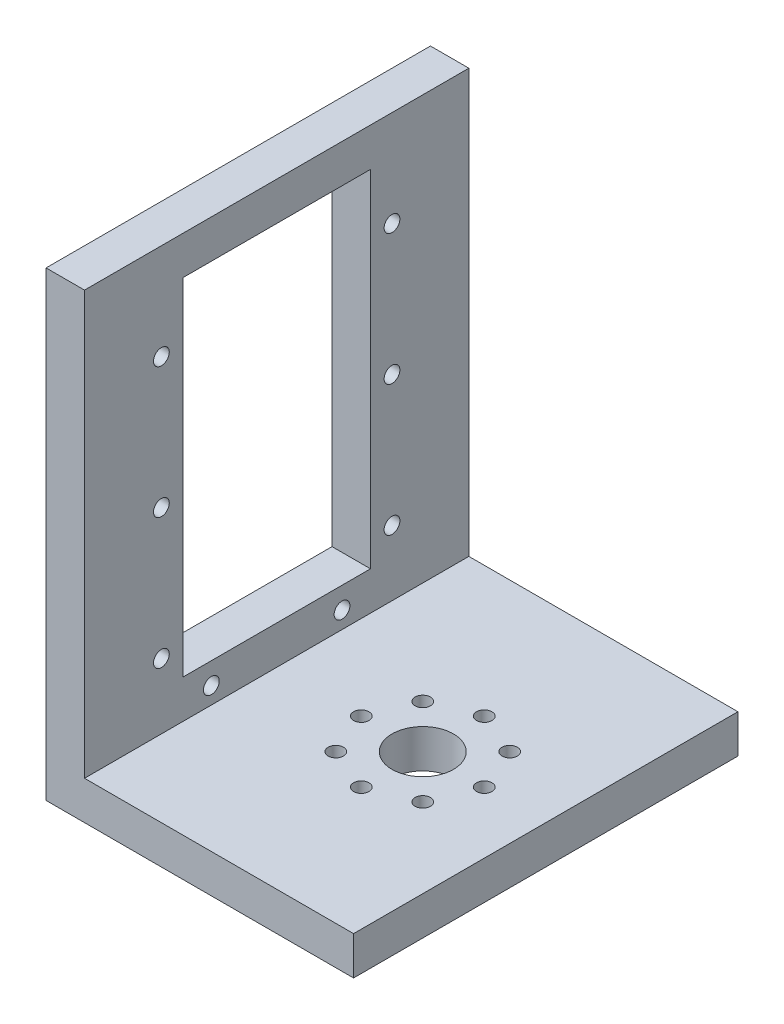
from build123d import *

# Parameters (mm, degrees)
SKETCH1_W           = 40
SKETCH1_H           = 50
SKETCH1_R           = 4
SKETCH1_R_2         = 1
BOSS_EXTRUDE1_DEPTH = 5
SKETCH3_W           = 5
SKETCH3_H           = 50
BOSS_EXTRUDE2_DEPTH = 60
SKETCH4_R           = 1.025
SKETCH4_W           = 24.4
SKETCH4_H           = 45
CUT_EXTRUDE1_DEPTH  = 41


with BuildPart() as part:
    # Sketch1 → Boss-Extrude1 (new body)
    with BuildSketch(Plane(origin=(0, 0, 0), x_dir=(1, 0, 0), z_dir=(0, 1, 0))):
        with Locations((20, 25)):
            Rectangle(SKETCH1_W, SKETCH1_H)
        with Locations((24, 25)):
            Circle(SKETCH1_R, mode=Mode.SUBTRACT)
        with Locations((24, 33)):
            Circle(SKETCH1_R_2, mode=Mode.SUBTRACT)
        with Locations((29.656854249, 30.656854249)):
            Circle(SKETCH1_R_2, mode=Mode.SUBTRACT)
        with Locations((32, 25)):
            Circle(SKETCH1_R_2, mode=Mode.SUBTRACT)
        with Locations((29.656854249, 19.343145751)):
            Circle(SKETCH1_R_2, mode=Mode.SUBTRACT)
        with Locations((24, 17)):
            Circle(SKETCH1_R_2, mode=Mode.SUBTRACT)
        with Locations((18.343145751, 19.343145751)):
            Circle(SKETCH1_R_2, mode=Mode.SUBTRACT)
        with Locations((16, 25)):
            Circle(SKETCH1_R_2, mode=Mode.SUBTRACT)
        with Locations((18.343145751, 30.656854249)):
            Circle(SKETCH1_R_2, mode=Mode.SUBTRACT)
    extrude(amount=BOSS_EXTRUDE1_DEPTH)

    # Sketch3 → Boss-Extrude2 (add)
    with BuildSketch(Plane(origin=(0, 0, 0), x_dir=(1, 0, 0), z_dir=(0, 1, 0))):
        with Locations((2.5, 25)):
            Rectangle(SKETCH3_W, SKETCH3_H)
    extrude(amount=BOSS_EXTRUDE2_DEPTH)

    # Sketch4 → Cut-Extrude1 (cut, through all)
    with BuildSketch(Plane.ZY):
        with Locations((-40, 47.5)):
            Circle(SKETCH4_R)
        with Locations((-10, 47.5)):
            Circle(SKETCH4_R)
        with Locations((-40, 30.5)):
            Circle(SKETCH4_R)
        with Locations((-10, 30.5)):
            Circle(SKETCH4_R)
        with Locations((-40, 13.5)):
            Circle(SKETCH4_R)
        with Locations((-33.5, 7.2)):
            Circle(SKETCH4_R)
        with Locations((-16.5, 7.2)):
            Circle(SKETCH4_R)
        with Locations((-10, 13.5)):
            Circle(SKETCH4_R)
        with Locations((-25, 32.5)):
            Rectangle(SKETCH4_W, SKETCH4_H)
    extrude(amount=-CUT_EXTRUDE1_DEPTH, mode=Mode.SUBTRACT)


solid = part.part
